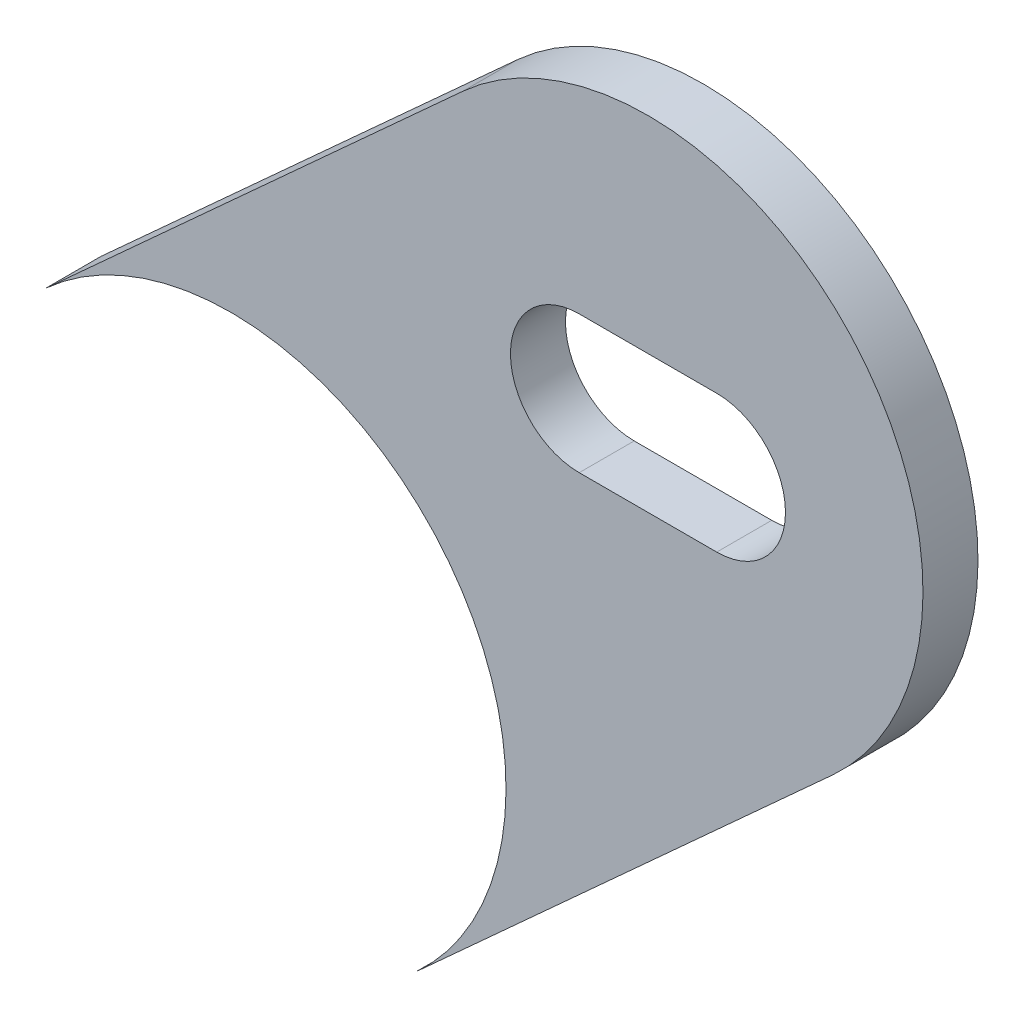
from build123d import *

# Parameters (mm, degrees)
BOSS_EXTRUDE3_START = 4.7625
BOSS_EXTRUDE3_DEPTH = 2.54


with BuildPart() as part:
    # Sketch2 → Boss-Extrude3 (new body)
    with BuildSketch(Plane.XY.offset(BOSS_EXTRUDE3_START)):
        with BuildLine():
            Line((-132.173225325, -84.582396488), (-112.918972687, -67.080031215))
            ThreePointArc((-112.918972687, -67.080031215), (-94.978825746, -67.935091298), (-95.833885829, -85.875238239))
            Line((-95.833885829, -85.875238239), (-115.088138468, -103.377603512))
            ThreePointArc((-115.088138468, -103.377603512), (-114.233078385, -85.437456571), (-132.173225325, -84.582396488))
        make_face()
        with BuildLine():
            Line((-107.551429258, -79.652634727), (-101.201429258, -79.652634727))
            ThreePointArc((-101.201429258, -79.652634727), (-98.026429258, -76.477634727), (-101.201429258, -73.302634727))
            Line((-101.201429258, -73.302634727), (-107.551429258, -73.302634727))
            ThreePointArc((-107.551429258, -73.302634727), (-110.726429258, -76.477634727), (-107.551429258, -79.652634727))
        make_face(mode=Mode.SUBTRACT)
    extrude(amount=BOSS_EXTRUDE3_DEPTH)


solid = part.part
